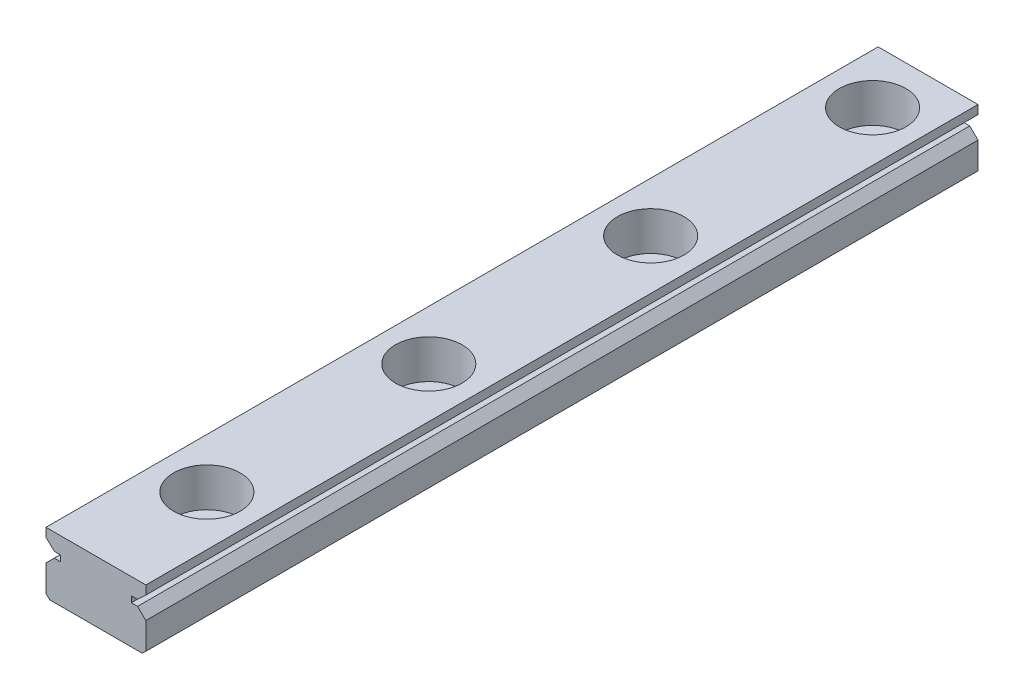
from build123d import *

# Parameters (mm, degrees)
EXTRUDE_1_DEPTH              = 75
HOLE_WIZARD_M6_1_D           = 3.5
HOLE_WIZARD_M6_1_DEPTH       = 5.495410489
HOLE_WIZARD_M6_1_CBORE_D     = 6
HOLE_WIZARD_M6_1_CBORE_DEPTH = 3.5


with BuildPart() as part:
    # Model → 凸台-拉伸1 (new body)
    with BuildSketch(Plane.XY):
        Polygon((172.467003798, 54.860433324), (176.62288374, 54.860433324), (180.778763681, 54.860433324), (181.122753743, 55.174540135), (181.122753743, 57.578663559), (180.378777275, 58.313663309), (179.814791529, 58.313663309), (179.814791529, 58.850465041), (180.366775583, 58.850465041), (181.122753743, 59.563028946), (181.122753743, 60.355843813), (176.62288374, 60.355843813), (172.123013736, 60.355843813), (172.123013736, 59.563028946), (172.878991897, 58.850465041), (173.43097595, 58.850465041), (173.43097595, 58.313663309), (172.866992243, 58.313663309), (172.123013736, 57.578663559), (172.123013736, 55.174540135), align=None)
    extrude(amount=EXTRUDE_1_DEPTH)

    # M6 六角头螺栓的柱形沉头孔1
    with Locations(Plane(origin=(176.62288374, 60.355843813, 5), x_dir=(0, 0, 1), z_dir=(0, 1, 0))):
        with Locations((0, 0), (20, 0), (40, 0), (60, 0)):
            CounterBoreHole(HOLE_WIZARD_M6_1_D / 2, HOLE_WIZARD_M6_1_CBORE_D / 2, HOLE_WIZARD_M6_1_CBORE_DEPTH, depth=HOLE_WIZARD_M6_1_DEPTH)


solid = part.part
